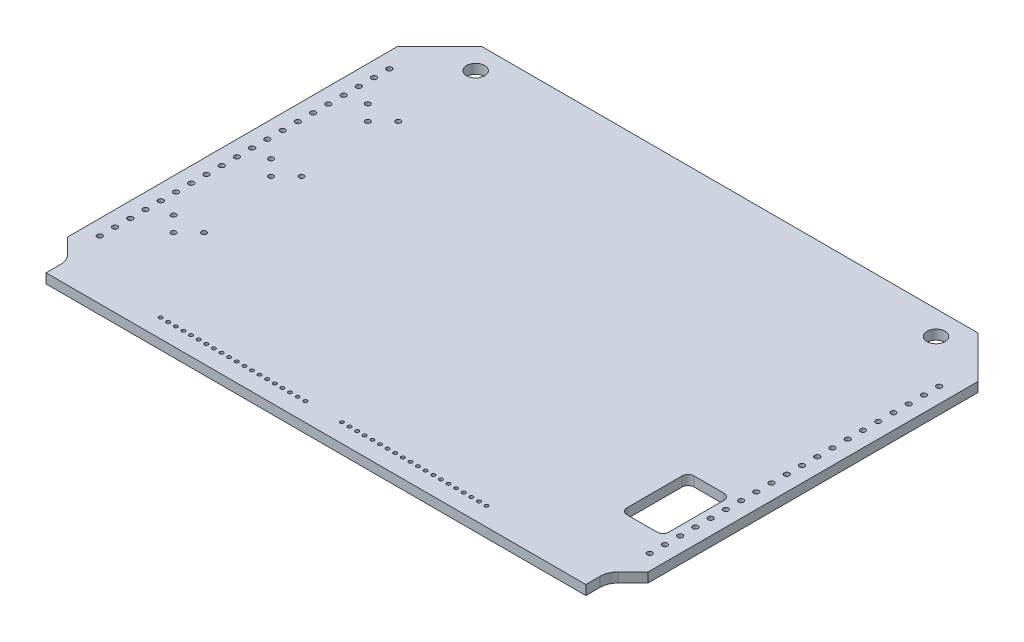
from build123d import *

# Parameters (mm, degrees)
BOSS_EXTRUDE1_DEPTH = 1.6
SKETCH3_W           = 15.2
SKETCH3_H           = 4
SKETCH3_W_2         = 12.95
SKETCH3_H_2         = 2.92
BOSS_EXTRUDE2_DEPTH = 2.5
FILLET1_R           = 3
SKETCH5_R           = 0.4318
CUT_EXTRUDE2_DEPTH  = 5.1
BOSS_EXTRUDE3_START = -1.6
BOSS_EXTRUDE3_DEPTH = 1.6
SKETCH7_R           = 1.5
CUT_EXTRUDE4_DEPTH  = 5.1
SKETCH8_R           = 0.3
SKETCH8_R_2         = 0.419
SKETCH8_W           = 6.99998401
SKETCH8_H           = 11.2
CUT_EXTRUDE5_DEPTH  = 2.6
FILLET2_R           = 1


with BuildPart() as part:
    # Sketch1 → Boss-Extrude1 (new body)
    with BuildSketch(Plane(origin=(0, 0, 0), x_dir=(1, 0, 0), z_dir=(0, 1, 0))):
        Polygon((48.3743, 0), (-48.3743, 0), (-48.3743, -55), (-45, -58.3743), (-45, -62), (45, -62), (45, -58.3743), (48.3743, -55), align=None)
    extrude(amount=BOSS_EXTRUDE1_DEPTH)

    # Sketch3 → Boss-Extrude2 (add)
    with BuildSketch(Plane.XZ):
        with Locations((24, 42.5)):
            Rectangle(SKETCH3_W, SKETCH3_H)
        with Locations((24, 42.5)):
            Rectangle(SKETCH3_W_2, SKETCH3_H_2, mode=Mode.SUBTRACT)
        with Locations((2.5, 42.5)):
            Rectangle(SKETCH3_W, SKETCH3_H)
        with Locations((2.5, 42.5)):
            Rectangle(SKETCH3_W_2, SKETCH3_H_2, mode=Mode.SUBTRACT)
        with Locations((24, 6.5)):
            Rectangle(SKETCH3_W, SKETCH3_H)
        with Locations((24, 6.5)):
            Rectangle(SKETCH3_W_2, SKETCH3_H_2, mode=Mode.SUBTRACT)
        with Locations((-1.500000054, 6.5)):
            Rectangle(SKETCH3_W, SKETCH3_H)
        with Locations((-1.500000054, 6.5)):
            Rectangle(SKETCH3_W_2, SKETCH3_H_2, mode=Mode.SUBTRACT)
    extrude(amount=BOSS_EXTRUDE2_DEPTH)

    # Fillet1
    fillet1_edges = [part.edges().sort_by_distance(p)[0] for p in [
        (45, 0.8, 58.3743),
        (-45, 0.8, 58.3743),
    ]]
    fillet(fillet1_edges, radius=FILLET1_R)

    # Sketch5 → Cut-Extrude2 (cut, through all)
    with BuildSketch(Plane(origin=(0, 1.6, 0), x_dir=(1, 0, 0), z_dir=(0, 1, 0))):
        with Locations((-45.8343, -3.937)):
            Circle(SKETCH5_R)
        with Locations((45.8343, -3.937)):
            Circle(SKETCH5_R)
        with Locations((-45.8343, -6.477)):
            Circle(SKETCH5_R)
        with Locations((45.8343, -6.477)):
            Circle(SKETCH5_R)
        with Locations((-45.8343, -9.017)):
            Circle(SKETCH5_R)
        with Locations((45.8343, -9.017)):
            Circle(SKETCH5_R)
        with Locations((-45.8343, -11.557)):
            Circle(SKETCH5_R)
        with Locations((45.8343, -11.557)):
            Circle(SKETCH5_R)
        with Locations((-45.8343, -14.097)):
            Circle(SKETCH5_R)
        with Locations((45.8343, -14.097)):
            Circle(SKETCH5_R)
        with Locations((-45.8343, -16.637)):
            Circle(SKETCH5_R)
        with Locations((45.8343, -16.637)):
            Circle(SKETCH5_R)
        with Locations((-45.8343, -19.177)):
            Circle(SKETCH5_R)
        with Locations((45.8343, -19.177)):
            Circle(SKETCH5_R)
        with Locations((-45.8343, -21.717)):
            Circle(SKETCH5_R)
        with Locations((45.8343, -21.717)):
            Circle(SKETCH5_R)
        with Locations((-45.8343, -24.257)):
            Circle(SKETCH5_R)
        with Locations((45.8343, -24.257)):
            Circle(SKETCH5_R)
        with Locations((-45.8343, -26.797)):
            Circle(SKETCH5_R)
        with Locations((45.8343, -26.797)):
            Circle(SKETCH5_R)
        with Locations((-45.8343, -29.337)):
            Circle(SKETCH5_R)
        with Locations((45.8343, -29.337)):
            Circle(SKETCH5_R)
        with Locations((-45.8343, -31.877)):
            Circle(SKETCH5_R)
        with Locations((45.8343, -31.877)):
            Circle(SKETCH5_R)
        with Locations((-45.8343, -34.417)):
            Circle(SKETCH5_R)
        with Locations((45.8343, -34.417)):
            Circle(SKETCH5_R)
        with Locations((-45.8343, -36.957)):
            Circle(SKETCH5_R)
        with Locations((45.8343, -36.957)):
            Circle(SKETCH5_R)
        with Locations((-45.8343, -39.497)):
            Circle(SKETCH5_R)
        with Locations((45.8343, -39.497)):
            Circle(SKETCH5_R)
        with Locations((-45.8343, -42.037)):
            Circle(SKETCH5_R)
        with Locations((45.8343, -42.037)):
            Circle(SKETCH5_R)
        with Locations((-45.8343, -44.577)):
            Circle(SKETCH5_R)
        with Locations((45.8343, -44.577)):
            Circle(SKETCH5_R)
        with Locations((-45.8343, -47.117)):
            Circle(SKETCH5_R)
        with Locations((45.8343, -47.117)):
            Circle(SKETCH5_R)
        with Locations((-45.8343, -49.657)):
            Circle(SKETCH5_R)
        with Locations((45.8343, -49.657)):
            Circle(SKETCH5_R)
        with Locations((-45.8343, -52.197)):
            Circle(SKETCH5_R)
        with Locations((45.8343, -52.197)):
            Circle(SKETCH5_R)
    extrude(amount=-CUT_EXTRUDE2_DEPTH, mode=Mode.SUBTRACT)

    # Sketch6 → Boss-Extrude3 (add)
    with BuildSketch(Plane(origin=(0, 1.6, 0), x_dir=(1, 0, 0), z_dir=(0, 1, 0)).offset(BOSS_EXTRUDE3_START)):
        Polygon((-48.3743, 0), (-41.3743, 7), (41.3743, 7), (48.3743, 0), align=None)
    extrude(amount=BOSS_EXTRUDE3_DEPTH)

    # Sketch7 → Cut-Extrude4 (cut, through all)
    with BuildSketch(Plane(origin=(0, 1.6, 0), x_dir=(1, 0, 0), z_dir=(0, 1, 0))):
        with Locations((-38.3743, 3)):
            Circle(SKETCH7_R)
        with Locations((38.3743, 3)):
            Circle(SKETCH7_R)
    extrude(amount=-CUT_EXTRUDE4_DEPTH, mode=Mode.SUBTRACT)

    # Sketch8 → Cut-Extrude5 (cut, through all)
    with BuildSketch(Plane.XZ):
        with Locations((25.362601124, 58.908128062)):
            Circle(SKETCH8_R)
        with Locations((24.092601124, 58.908125778)):
            Circle(SKETCH8_R)
        with Locations((22.822601124, 58.908123493)):
            Circle(SKETCH8_R)
        with Locations((21.552601124, 58.908121209)):
            Circle(SKETCH8_R)
        with Locations((20.282601124, 58.908118925)):
            Circle(SKETCH8_R)
        with Locations((19.012601124, 58.90811664)):
            Circle(SKETCH8_R)
        with Locations((17.742601124, 58.908114356)):
            Circle(SKETCH8_R)
        with Locations((16.472601124, 58.908112072)):
            Circle(SKETCH8_R)
        with Locations((15.202601124, 58.908109787)):
            Circle(SKETCH8_R)
        with Locations((13.932601124, 58.908107503)):
            Circle(SKETCH8_R)
        with Locations((12.662601124, 58.908105218)):
            Circle(SKETCH8_R)
        with Locations((11.392601124, 58.908102934)):
            Circle(SKETCH8_R)
        with Locations((10.122601124, 58.90810065)):
            Circle(SKETCH8_R)
        with Locations((8.852601124, 58.908098365)):
            Circle(SKETCH8_R)
        with Locations((7.582601124, 58.908096081)):
            Circle(SKETCH8_R)
        with Locations((6.312601124, 58.908093797)):
            Circle(SKETCH8_R)
        with Locations((5.042601124, 58.908091512)):
            Circle(SKETCH8_R)
        with Locations((3.772601124, 58.908089228)):
            Circle(SKETCH8_R)
        with Locations((2.502601124, 58.908086944)):
            Circle(SKETCH8_R)
        with Locations((1.232601124, 58.908084659)):
            Circle(SKETCH8_R)
        with Locations((-7.403398876, 58.908069126)):
            Circle(SKETCH8_R)
        with Locations((-8.673398876, 58.908066841)):
            Circle(SKETCH8_R)
        with Locations((-9.943398876, 58.908064557)):
            Circle(SKETCH8_R)
        with Locations((-11.213398876, 58.908062273)):
            Circle(SKETCH8_R)
        with Locations((-13.753398876, 58.908057704)):
            Circle(SKETCH8_R)
        with Locations((-15.023398876, 58.90805542)):
            Circle(SKETCH8_R)
        with Locations((-16.293398876, 58.908053135)):
            Circle(SKETCH8_R)
        with Locations((-17.563398876, 58.908050851)):
            Circle(SKETCH8_R)
        with Locations((-18.833398876, 58.908048567)):
            Circle(SKETCH8_R)
        with Locations((-20.103398876, 58.908046282)):
            Circle(SKETCH8_R)
        with Locations((-21.373398876, 58.908043998)):
            Circle(SKETCH8_R)
        with Locations((-22.643398876, 58.908041714)):
            Circle(SKETCH8_R)
        with Locations((-23.913398876, 58.908039429)):
            Circle(SKETCH8_R)
        with Locations((-25.183398876, 58.908037145)):
            Circle(SKETCH8_R)
        with Locations((-26.453398876, 58.908034861)):
            Circle(SKETCH8_R)
        with Locations((-27.723398876, 58.908032576)):
            Circle(SKETCH8_R)
        with Locations((-28.993398876, 58.908030292)):
            Circle(SKETCH8_R)
        with Locations((-42.709370322, 43.033005621)):
            Circle(SKETCH8_R_2)
        with Locations((-40.169374891, 45.57301019)):
            Circle(SKETCH8_R_2)
        with Locations((-37.629370322, 43.033014758)):
            Circle(SKETCH8_R_2)
        with Locations((-42.709341082, 26.777005621)):
            Circle(SKETCH8_R_2)
        with Locations((-40.169345651, 29.31701019)):
            Circle(SKETCH8_R_2)
        with Locations((-37.629341082, 26.777014758)):
            Circle(SKETCH8_R_2)
        with Locations((-42.5823123, 10.775005849)):
            Circle(SKETCH8_R_2)
        with Locations((-37.5023123, 10.775014987)):
            Circle(SKETCH8_R_2)
        with Locations((40.850280849, 42.906162167)):
            Rectangle(SKETCH8_W, SKETCH8_H)
        with Locations((-4.863398876, 58.908073694)):
            Circle(SKETCH8_R)
        with Locations((-6.133398876, 58.90807141)):
            Circle(SKETCH8_R)
        with Locations((-12.483398876, 58.908059988)):
            Circle(SKETCH8_R)
        with Locations((-40.042316868, 13.315010418)):
            Circle(SKETCH8_R_2)
    extrude(amount=-CUT_EXTRUDE5_DEPTH, mode=Mode.SUBTRACT)

    # Fillet2
    fillet2_edges = [part.edges().sort_by_distance(p)[0] for p in [
        (37.350288844, 0.8, 37.306162167),
        (37.350288844, 0.8, 48.506162167),
        (44.350272854, 0.8, 48.506162167),
        (44.350272854, 0.8, 37.306162167),
    ]]
    fillet(fillet2_edges, radius=FILLET2_R)


solid = part.part
